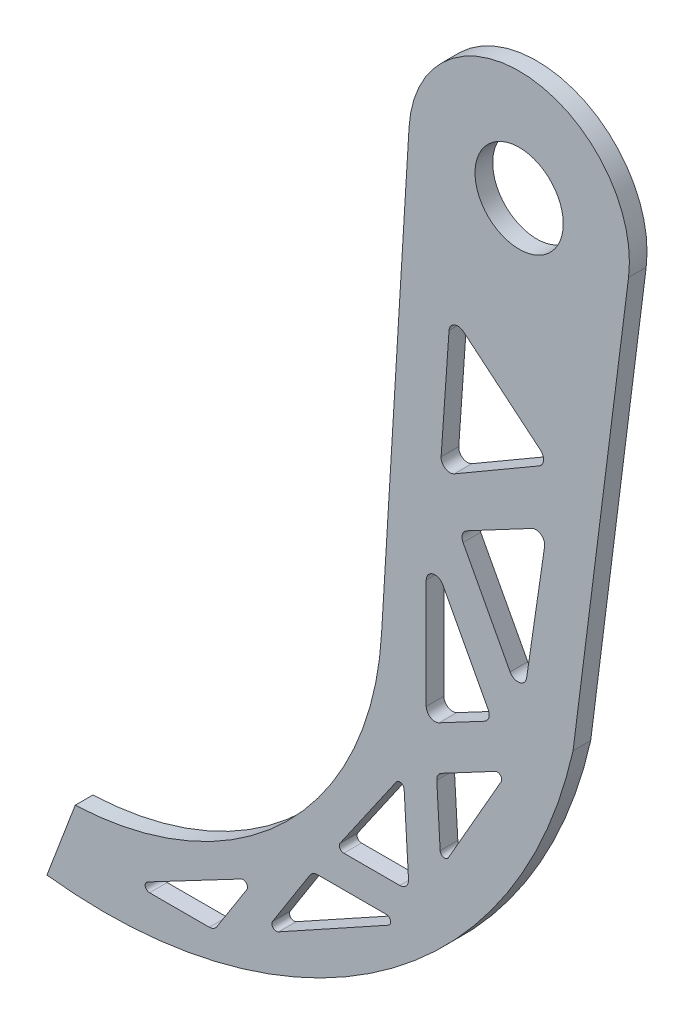
from build123d import *

# Parameters (mm, degrees)
BOSS_EXTRUDE1_DEPTH = 4
SKETCH1_3_R         = 10
CUT_EXTRUDE2_DEPTH  = 19.5
CUT_EXTRUDE3_DEPTH  = 59.5
FILLET2_R           = 2
FILLET9_R           = 2
FILLET10_R          = 1


with BuildPart() as part:
    # Sketch1 → Boss-Extrude1 (new body)
    with BuildSketch(Plane.XY):
        with BuildLine():
            Line((-24.953935647, 1.516936291), (-31.175265199, -100.825303282))
            ThreePointArc((-31.175265199, -100.825303282), (-52.615931746, -148.5955614), (-100.637442791, -169.467413729))
            Line((-100.637442791, -169.467413729), (-107.049597612, -186.395076324))
            ThreePointArc((-107.049597612, -186.395076324), (-31.236424704, -167.329888663), (12.223577372, -102.350301202))
            Line((12.223577372, -102.350301202), (24.801457775, -3.144470101))
            ThreePointArc((24.801457775, -3.144470101), (2.331949777, 24.891002596), (-24.953935647, 1.516936291))
        make_face()
    extrude(amount=BOSS_EXTRUDE1_DEPTH)

    # Sketch1_3 → Cut-Extrude2 (cut)
    with BuildSketch(Plane.XY):
        Circle(SKETCH1_3_R)
    extrude(amount=CUT_EXTRUDE2_DEPTH, mode=Mode.SUBTRACT)

    # Sketch1_4 → Cut-Extrude3 (cut)
    with BuildSketch(Plane.XY):
        Polygon((6.347009132, -61.537145709), (-13.655055469, -72.161869066), (0.810016745, -99.393760114), align=None)
        Polygon((-21.064699943, -77.437028338), (-6.079431787, -105.648238327), (-21.064699943, -113.608133056), align=None)
        Polygon((-26.234337885, -155.650813652), (-46.824530665, -155.650813652), (-57.99672275, -173.202762284), align=None)
        Polygon((-59.711910653, -163.410469366), (-69.148377202, -178.235525617), (-87.829466791, -178.235525617), align=None)
        Polygon((-26.234337885, -126.17530166), (-24.953935647, -148.446836425), (-41.663691875, -148.446836425), align=None)
        Polygon((-18.747269764, -122.305223747), (-2.374159237, -113.608133056), (-17.707255347, -140.395411768), align=None)
        Polygon((-17.949592316, -63.337916036), (7.016311499, -48.830036106), (-15.620624799, -29.988511388), align=None)
    extrude(amount=CUT_EXTRUDE3_DEPTH, mode=Mode.SUBTRACT)

    # Fillet2
    fillet2_edges = [part.edges().sort_by_distance(p)[0] for p in [
        (-6.079431787, -105.648238327, 2),
        (-21.064699943, -113.608133056, 2),
        (-21.064699943, -77.437028338, 2),
        (6.347009132, -61.537145709, 2),
        (0.810016745, -99.393760114, 2),
        (-13.655055469, -72.161869066, 2),
        (-15.620624799, -29.988511388, 2),
        (7.016311499, -48.830036106, 2),
        (-17.949592316, -63.337916036, 2),
    ]]
    fillet(fillet2_edges, radius=FILLET2_R)

    # Fillet9
    fillet9_edges = [part.edges().sort_by_distance(p)[0] for p in [
        (-69.148377202, -178.235525617, 2),
        (-46.824530665, -155.650813652, 2),
        (-24.953935647, -148.446836425, 2),
        (-18.747269764, -122.305223747, 2),
    ]]
    fillet(fillet9_edges, radius=FILLET9_R)

    # Fillet10
    fillet10_edges = [part.edges().sort_by_distance(p)[0] for p in [
        (-59.711910653, -163.410469366, 2),
        (-87.829466791, -178.235525617, 2),
        (-57.99672275, -173.202762284, 2),
        (-26.234337885, -155.650813652, 2),
        (-41.663691875, -148.446836425, 2),
        (-17.707255347, -140.395411768, 2),
        (-26.234337885, -126.17530166, 2),
        (-2.374159237, -113.608133056, 2),
    ]]
    fillet(fillet10_edges, radius=FILLET10_R)


solid = part.part
